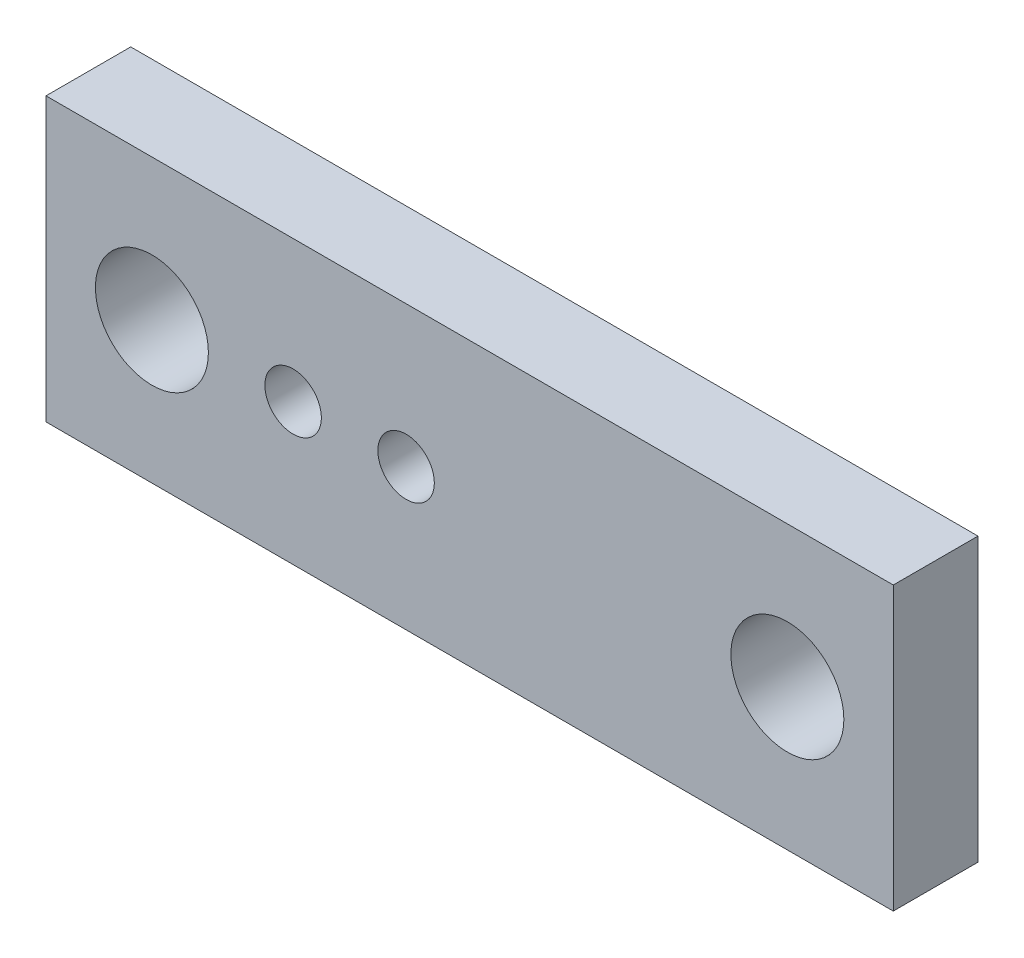
from build123d import *

# Parameters (mm, degrees)
SKETCH_1_W          = 60
SKETCH_1_H          = 20
SKETCH_1_R          = 4
SKETCH_1_R_2        = 2
EXTRUDE_1_DEPTH     = 6
CUT_EXTRUDE_1_DEPTH = 3


with BuildPart() as part:
    # 草圖1 → 填料-伸長1 (new body)
    with BuildSketch(Plane.XY):
        with Locations((30, 10)):
            Rectangle(SKETCH_1_W, SKETCH_1_H)
        with Locations((7.5, 10)):
            Circle(SKETCH_1_R, mode=Mode.SUBTRACT)
        with Locations((17.5, 10)):
            Circle(SKETCH_1_R_2, mode=Mode.SUBTRACT)
        with Locations((25.5, 10)):
            Circle(SKETCH_1_R_2, mode=Mode.SUBTRACT)
        with Locations((52.5, 10)):
            Circle(SKETCH_1_R, mode=Mode.SUBTRACT)
    extrude(amount=EXTRUDE_1_DEPTH)

    # 草圖3 → 除料-伸長1 (cut)
    with BuildSketch(Plane(origin=(0, 0, 0), x_dir=(-1, 0, 0), z_dir=(0, 0, -1))):
        with BuildLine():
            Line((-25.5, 12.75), (-17.5, 12.75))
            ThreePointArc((-17.5, 12.75), (-14.75, 10), (-17.5, 7.25))
            Line((-17.5, 7.25), (-25.5, 7.25))
            ThreePointArc((-25.5, 7.25), (-28.25, 10), (-25.5, 12.75))
        make_face()
    extrude(amount=-CUT_EXTRUDE_1_DEPTH, mode=Mode.SUBTRACT)


solid = part.part
